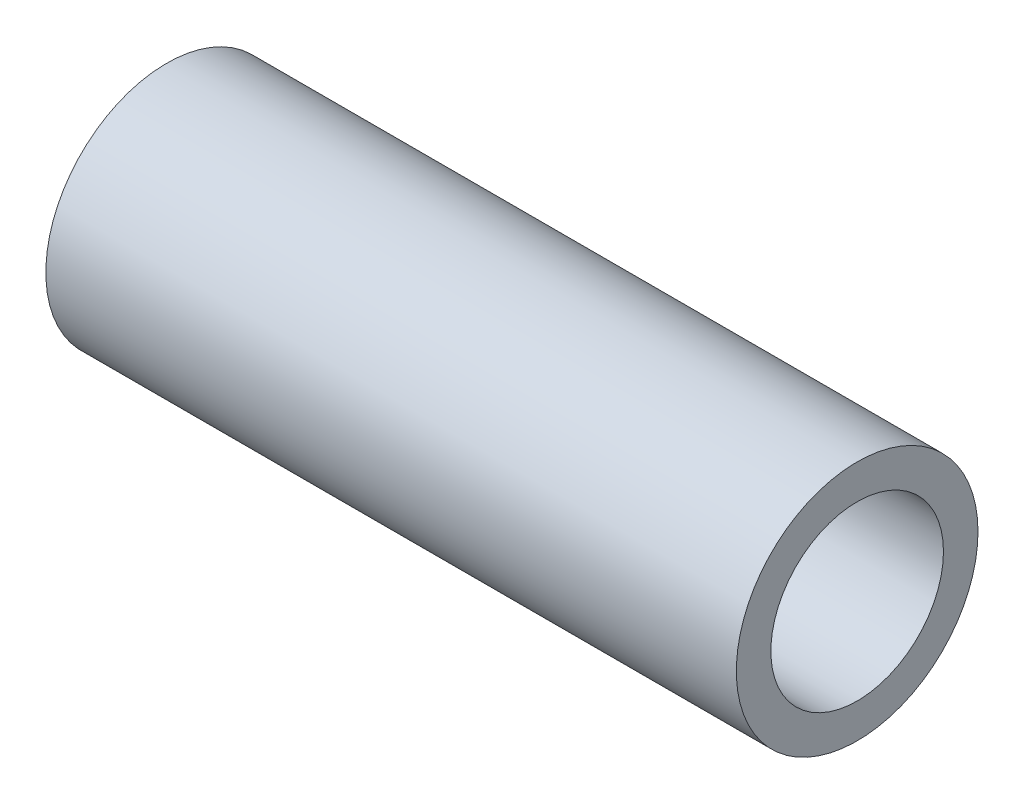
from build123d import *

# Parameters (mm, degrees)
SKETCH1_R           = 5.55625
SKETCH1_R_2         = 3.96875
BOSS_EXTRUDE1_DEPTH = 15.875


with BuildPart() as part:
    # Sketch1 → Boss-Extrude1 (new body, symmetric)
    with BuildSketch(Plane(origin=(0, 0, 0), x_dir=(0, 0, -1), z_dir=(1, 0, 0))):
        Circle(SKETCH1_R)
        Circle(SKETCH1_R_2, mode=Mode.SUBTRACT)
    extrude(amount=BOSS_EXTRUDE1_DEPTH, both=True)


solid = part.part
